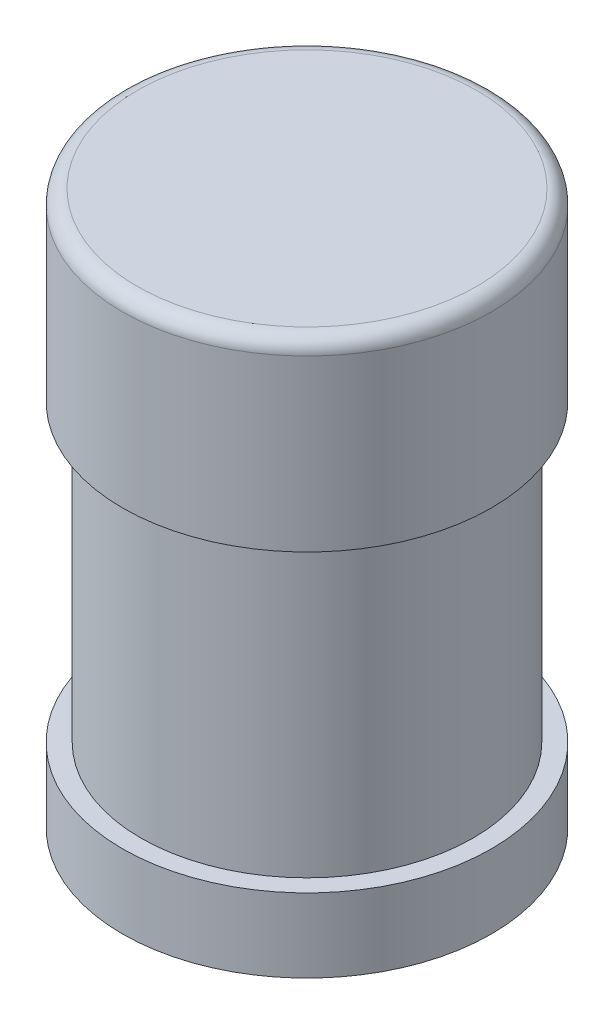
from build123d import *

# Parameters (mm, degrees)
SHELL4_T  = -1
FILLET1_R = 0.4
FILLET2_R = 0.4
FILLET3_R = 0.4


with BuildPart() as part:
    # Sketch1 → Revolve2 (revolve)
    with BuildSketch(Plane.XY, mode=Mode.PRIVATE) as revolve2_sk:
        Polygon((0, 15), (-5, 15), (-5, 10), (-4.5, 10), (-4.5, 2), (-5, 2), (-5, 0), (0, 0), align=None)
    revolve(revolve2_sk.sketch.rotate(Axis((0, 0, 0), (0, 1, 0)), 270), axis=Axis((0, 0, 0), (0, 1, 0)))

    # Shell4
    shell4_openings = [part.faces().sort_by_distance(p)[0] for p in [
        (0, 0, 0),
    ]]
    offset(amount=SHELL4_T, openings=shell4_openings, kind=Kind.INTERSECTION)

    # Fillet1
    fillet1_edges = [part.edges().sort_by_distance(p)[0] for p in [
        (0, 15, 5),
    ]]
    fillet(fillet1_edges, radius=FILLET1_R)

    # Fillet2
    fillet2_edges = [part.edges().sort_by_distance(p)[0] for p in [
        (0, 1, 3.5),
    ]]
    fillet(fillet2_edges, radius=FILLET2_R)

    # Fillet3
    fillet3_edges = [part.edges().sort_by_distance(p)[0] for p in [
        (0, 11, 3.5),
    ]]
    fillet(fillet3_edges, radius=FILLET3_R)


solid = part.part
